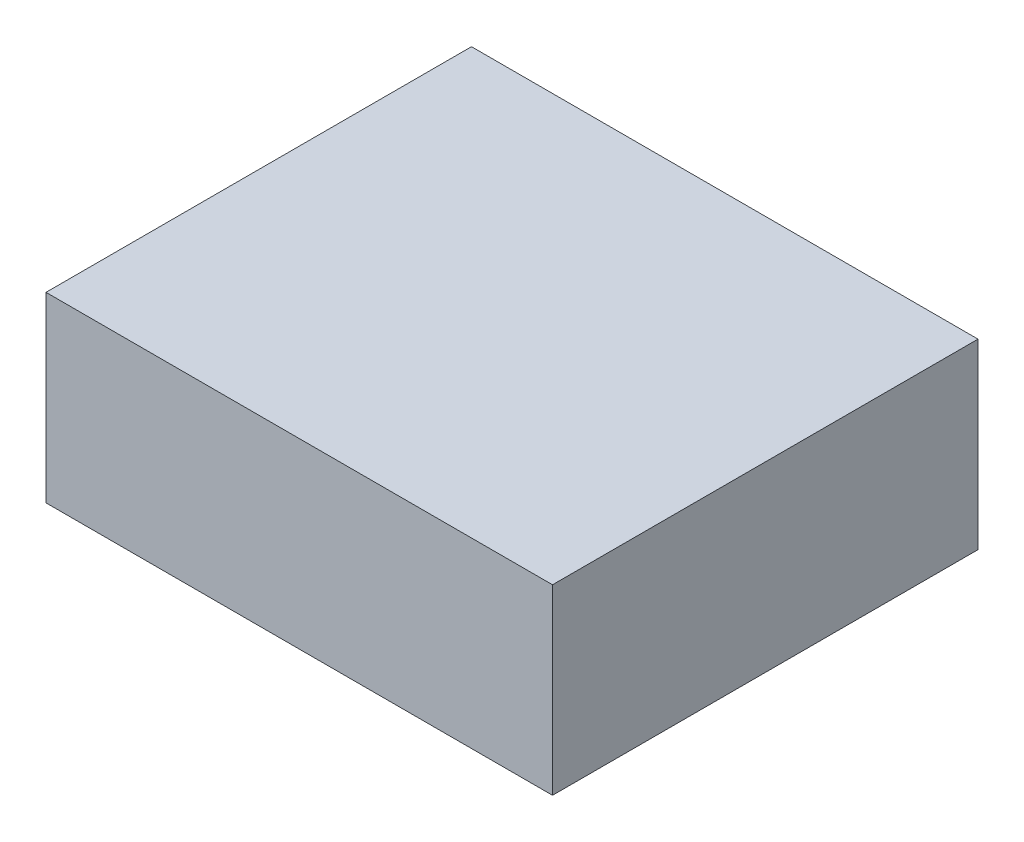
from build123d import *

# Parameters (mm, degrees)
BOSS_EXTRUDE1_DEPTH      = 4.5
BOSS_EXTRUDE1_DEPTH_BACK = 4.5
SKETCH2_W                = 25
SKETCH2_H                = 21


with BuildPart() as part:
    # Sketch2 → Boss-Extrude1 (new, two sides: drawn at the far end of the back side and taken through both)
    with BuildSketch(Plane(origin=(0, 0, 0), x_dir=(1, 0, 0), z_dir=(0, 1, 0)).offset(-BOSS_EXTRUDE1_DEPTH_BACK)):
        Rectangle(SKETCH2_W, SKETCH2_H)
    extrude(amount=BOSS_EXTRUDE1_DEPTH + BOSS_EXTRUDE1_DEPTH_BACK)


solid = part.part
